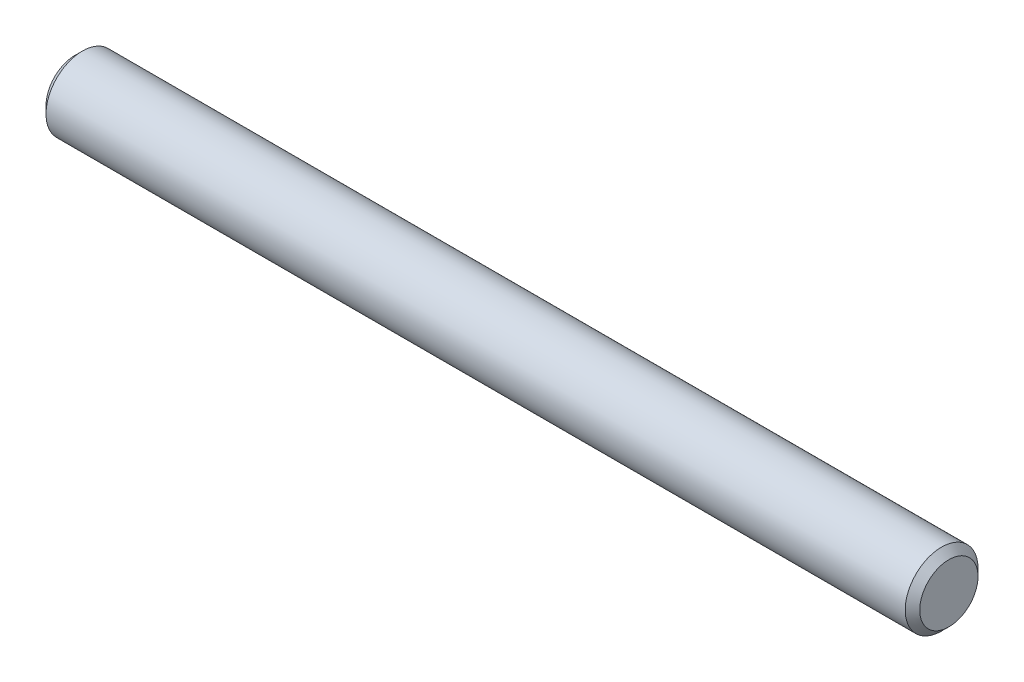
from build123d import *

# Parameters (mm, degrees)
SKETCH2_R           = 1.5875
EXTRUDE1_DEPTH      = 19.05
EXTRUDE1_DEPTH_BACK = 19.05
CHAMFER1_SIZE       = 0.3175


with BuildPart() as part:
    # Sketch2 → Extrude1 (new body, two sides)
    with BuildSketch(Plane(origin=(0, 0, 0), x_dir=(0, 0, -1), z_dir=(1, 0, 0))) as extrude1_sk:
        Circle(SKETCH2_R)
    extrude(amount=EXTRUDE1_DEPTH)
    extrude(extrude1_sk.sketch, amount=-EXTRUDE1_DEPTH_BACK)

    # Chamfer1
    chamfer1_edges = [part.edges().sort_by_distance(p)[0] for p in [
        (-19.05, 0, 1.5875),
        (19.05, 0, 1.5875),
    ]]
    chamfer(chamfer1_edges, length=CHAMFER1_SIZE)


solid = part.part
